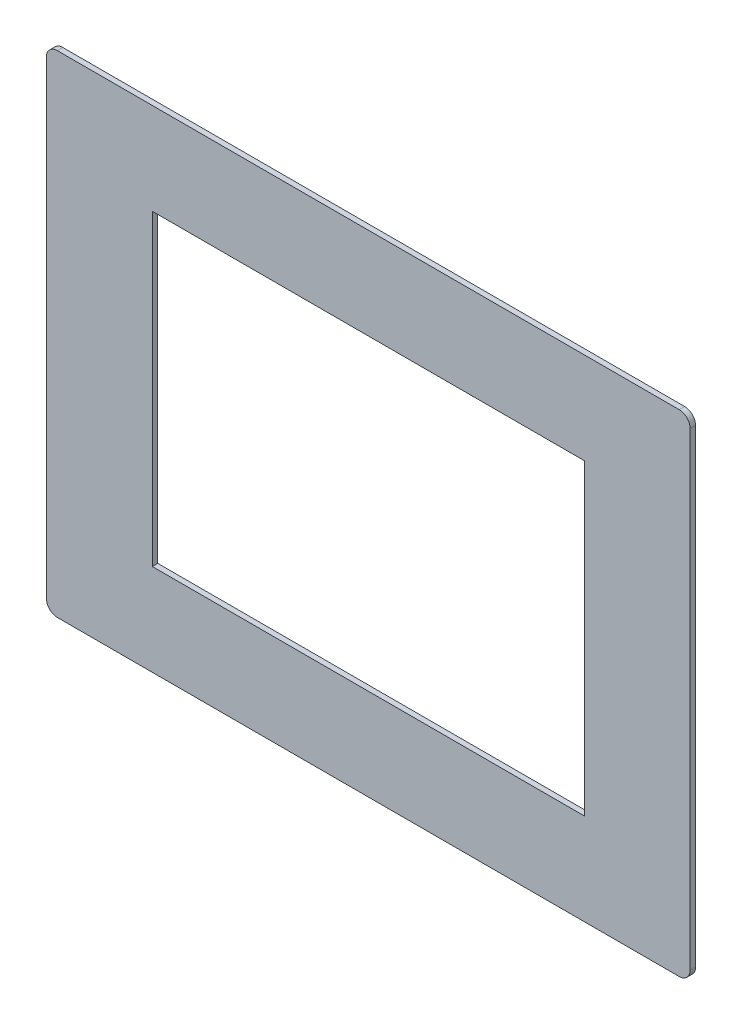
from build123d import *

# Parameters (mm, degrees)
SKETCH1_W           = 295
SKETCH1_H           = 225
SKETCH1_W_2         = 198
SKETCH1_H_2         = 141
BOSS_EXTRUDE1_DEPTH = 2.5
FILLET1_R           = 5


with BuildPart() as part:
    # Sketch1 → Boss-Extrude1 (new body)
    with BuildSketch(Plane.XY):
        Rectangle(SKETCH1_W, SKETCH1_H)
        Rectangle(SKETCH1_W_2, SKETCH1_H_2, mode=Mode.SUBTRACT)
    extrude(amount=BOSS_EXTRUDE1_DEPTH)

    # Fillet1
    fillet1_edges = [part.edges().sort_by_distance(p)[0] for p in [
        (147.5, -112.5, 1.25),
        (-147.5, -112.5, 1.25),
        (-147.5, 112.5, 1.25),
        (147.5, 112.5, 1.25),
    ]]
    fillet(fillet1_edges, radius=FILLET1_R)


solid = part.part
